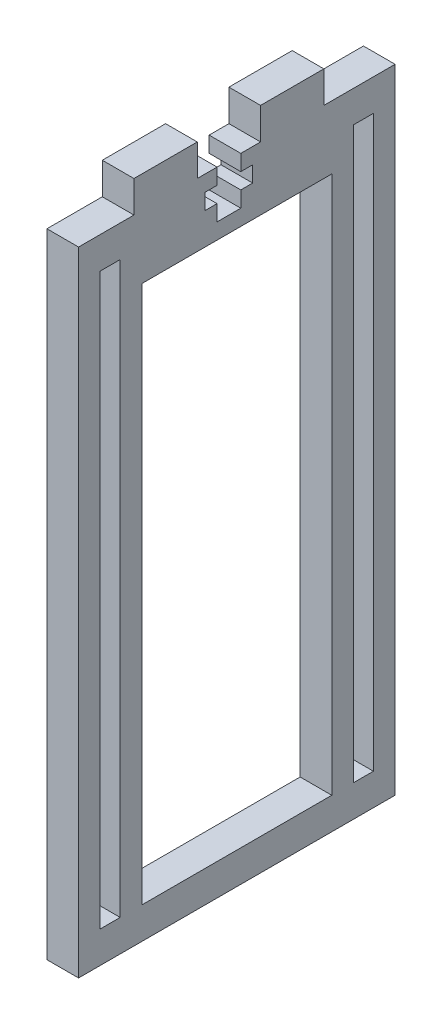
from build123d import *

# Parameters (mm, degrees)
BOSS_EXTRUDE1_DEPTH = 6.35
SKETCH4_W           = 4.7625
SKETCH4_H           = 9.525
SKETCH4_W_2         = 9.525
SKETCH4_H_2         = 3.175
CUT_EXTRUDE1_DEPTH  = 6.35
SKETCH6_W           = 38.1
SKETCH6_H           = 6.35
BOSS_EXTRUDE3_DEPTH = 6.35


with BuildPart() as part:
    # Sketch2 → Boss-Extrude1 (new body)
    with BuildSketch(Plane(origin=(0, 0, 0), x_dir=(0, 0, -1), z_dir=(1, 0, 0))):
        Polygon((0, 127), (0, 0), (12.7, 0), (12.7, 114.3), (15.875, 114.3), (50.8, 114.3), (50.8, 0), (63.5, 0), (63.5, 114.3), (63.5, 127), (49.2125, 127), (49.2125, 133.35), (36.5125, 133.35), (36.5125, 127), (23.8125, 127), (23.8125, 133.35), (11.1125, 133.35), (11.1125, 127), align=None)
        Polygon((4.35, 6.35), (4.35, 120.65), (6.35, 120.65), (8.35, 120.65), (8.35, 6.35), align=None, mode=Mode.SUBTRACT)
        Polygon((59.15, 120.65), (59.15, 114.3), (59.15, 6.35), (55.15, 6.35), (55.15, 114.3), (55.15, 120.65), (57.15, 120.65), align=None, mode=Mode.SUBTRACT)
    extrude(amount=BOSS_EXTRUDE1_DEPTH)

    # Sketch4 → Cut-Extrude1 (cut)
    with BuildSketch(Plane.ZY):
        with Locations((-30.1625, 122.2375)):
            Rectangle(SKETCH4_W, SKETCH4_H)
        with Locations((-30.1625, 122.2375)):
            Rectangle(SKETCH4_W_2, SKETCH4_H_2)
    extrude(amount=-CUT_EXTRUDE1_DEPTH, mode=Mode.SUBTRACT)

    # Sketch6 → Boss-Extrude3 (add)
    with BuildSketch(Plane(origin=(6.35, 0, 0), x_dir=(0, 0, -1), z_dir=(1, 0, 0))):
        with Locations((31.75, 3.175)):
            Rectangle(SKETCH6_W, SKETCH6_H)
    extrude(amount=-BOSS_EXTRUDE3_DEPTH)


solid = part.part
